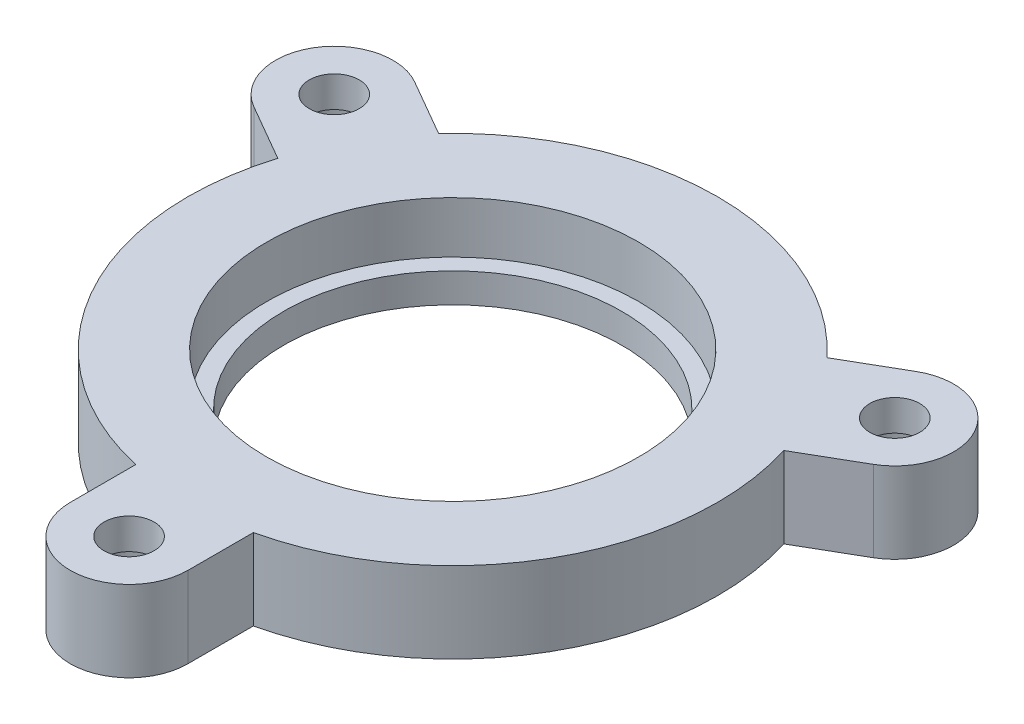
from build123d import *

# Parameters (mm, degrees)
SKETCH1_R                                           = 11.5
BOSS_EXTRUDE1_DEPTH                                 = 5.5
CUT_EXTRUDE1_START                                  = 2
SKETCH1_3_R                                         = 12.65
CUT_EXTRUDE1_DEPTH                                  = 3.5
CBORE_FOR_M3_HEX_SOCKET_HEAD_CAP_SCREW1_D           = 3.4
CBORE_FOR_M3_HEX_SOCKET_HEAD_CAP_SCREW1_DEPTH       = 45
CBORE_FOR_M3_HEX_SOCKET_HEAD_CAP_SCREW1_CBORE_D     = 6.5
CBORE_FOR_M3_HEX_SOCKET_HEAD_CAP_SCREW1_CBORE_DEPTH = 3.4
CBORE_FOR_M3_HEX_SOCKET_HEAD_CAP_SCREW1_TIP         = 1.021463052


with BuildPart() as part:
    # Sketch1 → Boss-Extrude1 (new body)
    with BuildSketch(Plane(origin=(0, 0, 0), x_dir=(1, 0, 0), z_dir=(0, 1, 0))):
        with BuildLine():
            ThreePointArc((-4, -22), (0, -26), (4, -22))
            Line((4, -22), (4, -17.549928775))
            ThreePointArc((4, -17.549928775), (15.588457268, -9), (17.198684154, 5.310862772))
            Line((17.198684154, 5.310862772), (21.052558883, 7.535898385))
            ThreePointArc((21.052558883, 7.535898385), (22.516660498, 13), (17.052558883, 14.464101615))
            Line((17.052558883, 14.464101615), (13.198684154, 12.239066003))
            ThreePointArc((13.198684154, 12.239066003), (0, 18), (-13.198684154, 12.239066003))
            Line((-13.198684154, 12.239066003), (-17.052558883, 14.464101615))
            ThreePointArc((-17.052558883, 14.464101615), (-22.516660498, 13), (-21.052558883, 7.535898385))
            Line((-21.052558883, 7.535898385), (-17.198684154, 5.310862772))
            ThreePointArc((-17.198684154, 5.310862772), (-15.588457268, -9), (-4, -17.549928775))
            Line((-4, -17.549928775), (-4, -22))
        make_face()
        Circle(SKETCH1_R, mode=Mode.SUBTRACT)
    extrude(amount=BOSS_EXTRUDE1_DEPTH)

    # Sketch1_3 → Cut-Extrude1 (cut)
    with BuildSketch(Plane(origin=(0, 0, 0), x_dir=(1, 0, 0), z_dir=(0, 1, 0)).offset(CUT_EXTRUDE1_START)):
        Circle(SKETCH1_3_R)
    extrude(amount=CUT_EXTRUDE1_DEPTH, mode=Mode.SUBTRACT)

    # CBORE for M3 Hex Socket Head Cap Screw1
    with Locations(Plane.XZ):
        with Locations((-19.052558883, -11), (19.052558883, -11), (0, 22)):
            CounterBoreHole(CBORE_FOR_M3_HEX_SOCKET_HEAD_CAP_SCREW1_D / 2, CBORE_FOR_M3_HEX_SOCKET_HEAD_CAP_SCREW1_CBORE_D / 2, CBORE_FOR_M3_HEX_SOCKET_HEAD_CAP_SCREW1_CBORE_DEPTH, depth=CBORE_FOR_M3_HEX_SOCKET_HEAD_CAP_SCREW1_DEPTH)
            with Locations((0, 0, -(CBORE_FOR_M3_HEX_SOCKET_HEAD_CAP_SCREW1_DEPTH + CBORE_FOR_M3_HEX_SOCKET_HEAD_CAP_SCREW1_TIP / 2))):  # 118° drill point
                Cone(0, CBORE_FOR_M3_HEX_SOCKET_HEAD_CAP_SCREW1_D / 2, CBORE_FOR_M3_HEX_SOCKET_HEAD_CAP_SCREW1_TIP, mode=Mode.SUBTRACT)


solid = part.part
